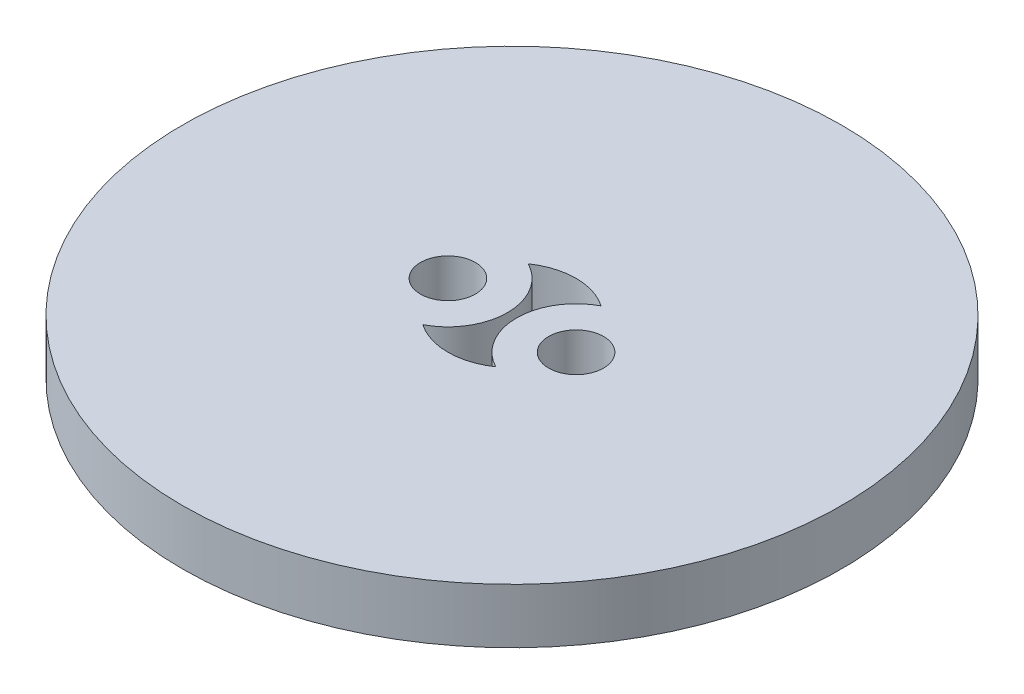
from build123d import *

# Parameters (mm, degrees)
ESQUISSE1_R        = 18
ESQUISSE1_R_2      = 1.5
BOSS_EXTRU_1_DEPTH = 3


with BuildPart() as part:
    # Esquisse1 → Boss.-Extru.1 (new body)
    with BuildSketch(Plane(origin=(0, 0, 0), x_dir=(1, 0, 0), z_dir=(0, 1, 0))):
        Circle(ESQUISSE1_R)
        with Locations((-3.5, 0)):
            Circle(ESQUISSE1_R_2, mode=Mode.SUBTRACT)
        with Locations((3.5, 0)):
            Circle(ESQUISSE1_R_2, mode=Mode.SUBTRACT)
        with BuildLine():
            ThreePointArc((1.991071429, 2.878477821), (0.25, 0), (1.991071429, -2.878477821))
            ThreePointArc((1.991071429, -2.878477821), (0, -3.5), (-1.991071429, -2.878477821))
            ThreePointArc((-1.991071429, -2.878477821), (-0.25, 0), (-1.991071429, 2.878477821))
            ThreePointArc((-1.991071429, 2.878477821), (0, 3.5), (1.991071429, 2.878477821))
        make_face(mode=Mode.SUBTRACT)
    extrude(amount=BOSS_EXTRU_1_DEPTH)


solid = part.part
